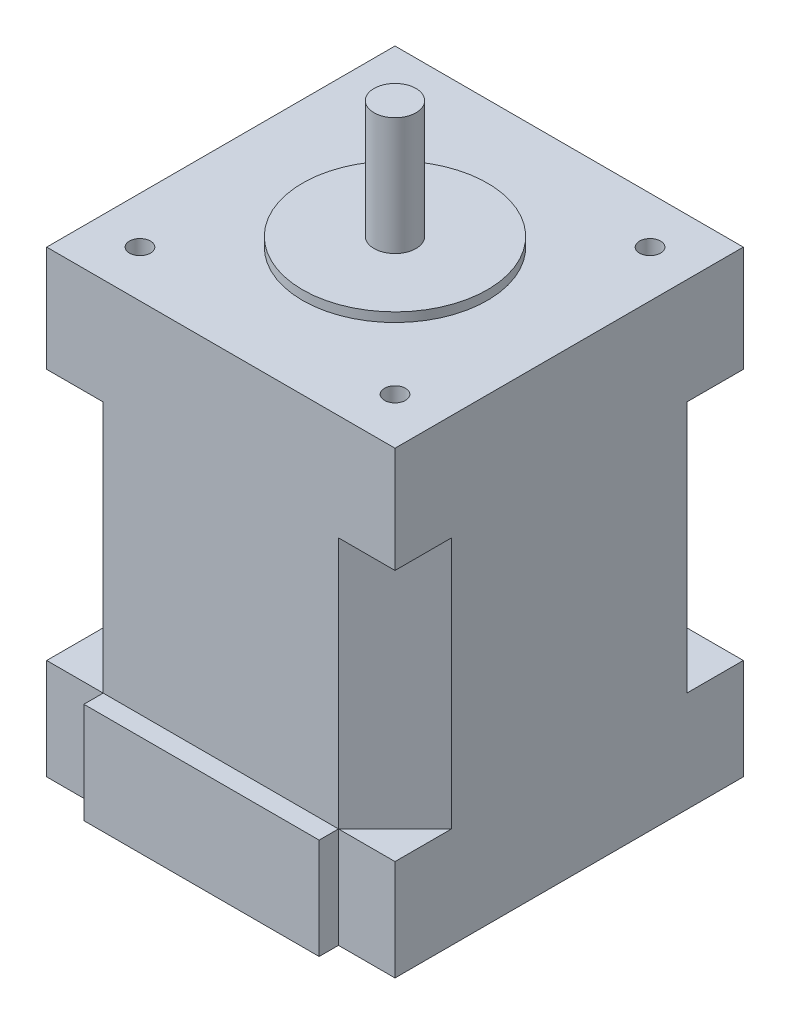
from build123d import *

# Parameters (mm, degrees)
SKETCH1_W               = 41.45
SKETCH1_H               = 41.45
BOSS_EXTRUDE1_DEPTH     = 54.6
SKETCH2_R               = 11
BOSS_EXTRUDE2_DEPTH     = 1.1
SKETCH3_R               = 2.5
BOSS_EXTRUDE3_DEPTH     = 14
BOSS_EXTRUDE4_DEPTH     = 12
SKETCH5_R               = 1.25
CUT_EXTRUDE1_DEPTH      = 12
MIRROR2_COPY_1_SKETCH_R = 1.25
MIRROR2_COPY_1_DEPTH    = 12
CUT_EXTRUDE2_DEPTH      = 30
MIRROR4_COPY_1_DEPTH    = 30
SKETCH10_R              = 4.45
CUT_EXTRUDE3_DEPTH      = 6


with BuildPart() as part:
    # Sketch1 → Boss-Extrude1 (new body)
    with BuildSketch(Plane(origin=(0, 0, 0), x_dir=(1, 0, 0), z_dir=(0, 1, 0))):
        Rectangle(SKETCH1_W, SKETCH1_H)
    extrude(amount=BOSS_EXTRUDE1_DEPTH)

    # Sketch2 → Boss-Extrude2 (add)
    with BuildSketch(Plane(origin=(0, 54.6, 0), x_dir=(1, 0, 0), z_dir=(0, 1, 0))):
        Circle(SKETCH2_R)
    extrude(amount=BOSS_EXTRUDE2_DEPTH)

    # Sketch3 → Boss-Extrude3 (add)
    with BuildSketch(Plane(origin=(0, 55.7, 0), x_dir=(1, 0, 0), z_dir=(0, 1, 0))):
        Circle(SKETCH3_R)
    extrude(amount=BOSS_EXTRUDE3_DEPTH)

    # Sketch4 → Boss-Extrude4 (add)
    with BuildSketch(Plane.XZ):
        Polygon((0, 20.725), (14, 20.725), (14, 23.025), (-14, 23.025), (-14, 20.725), align=None)
    extrude(amount=-BOSS_EXTRUDE4_DEPTH)

    # Sketch5 → Cut-Extrude1 (cut)
    with BuildSketch(Plane(origin=(0, 54.6, 0), x_dir=(1, 0, 0), z_dir=(0, 1, 0))):
        with Locations((15.175, 15.175)):
            Circle(SKETCH5_R)
    cut_extrude1 = extrude(amount=-CUT_EXTRUDE1_DEPTH, mode=Mode.SUBTRACT)

    # Mirror1: Cut-Extrude1 across plane
    add(cut_extrude1.mirror(Plane.XY), mode=Mode.SUBTRACT)

    # Mirror2: Cut-Extrude1 across plane
    add(cut_extrude1.mirror(Plane(origin=(0, 0, 0), x_dir=(0, 0, 1), z_dir=(1, 0, 0))), mode=Mode.SUBTRACT)

    # Mirror2 copy 1 sketch → Mirror2 copy 1 (cut)
    with BuildSketch(Plane(origin=(0, 54.6, 0), x_dir=(-1, 0, 0), z_dir=(0, 1, 0))):
        with Locations((15.175, 15.175)):
            Circle(MIRROR2_COPY_1_SKETCH_R)
    extrude(amount=-MIRROR2_COPY_1_DEPTH, mode=Mode.SUBTRACT)

    # Sketch8 → Cut-Extrude2 (cut)
    with BuildSketch(Plane(origin=(0, 12, 0), x_dir=(1, 0, 0), z_dir=(0, 1, 0))):
        Polygon((-20.725, 14), (-20.725, 20.725), (-14, 20.725), align=None)
    cut_extrude2 = extrude(amount=CUT_EXTRUDE2_DEPTH, mode=Mode.SUBTRACT)

    # Mirror3: Cut-Extrude2 across plane
    add(cut_extrude2.mirror(Plane(origin=(0, 0, 0), x_dir=(0, 0, 1), z_dir=(1, 0, 0))), mode=Mode.SUBTRACT)

    # Mirror4: Cut-Extrude2 across plane
    add(cut_extrude2.mirror(Plane.XY), mode=Mode.SUBTRACT)

    # Mirror4 copy 1 sketch → Mirror4 copy 1 (cut)
    with BuildSketch(Plane(origin=(0, 12, 0), x_dir=(-1, 0, 0), z_dir=(0, 1, 0))):
        Polygon((-20.725, 14), (-20.725, 20.725), (-14, 20.725), align=None)
    extrude(amount=MIRROR4_COPY_1_DEPTH, mode=Mode.SUBTRACT)

    # Sketch10 → Cut-Extrude3 (cut)
    with BuildSketch(Plane.XZ):
        Circle(SKETCH10_R)
    extrude(amount=-CUT_EXTRUDE3_DEPTH, mode=Mode.SUBTRACT)


solid = part.part
